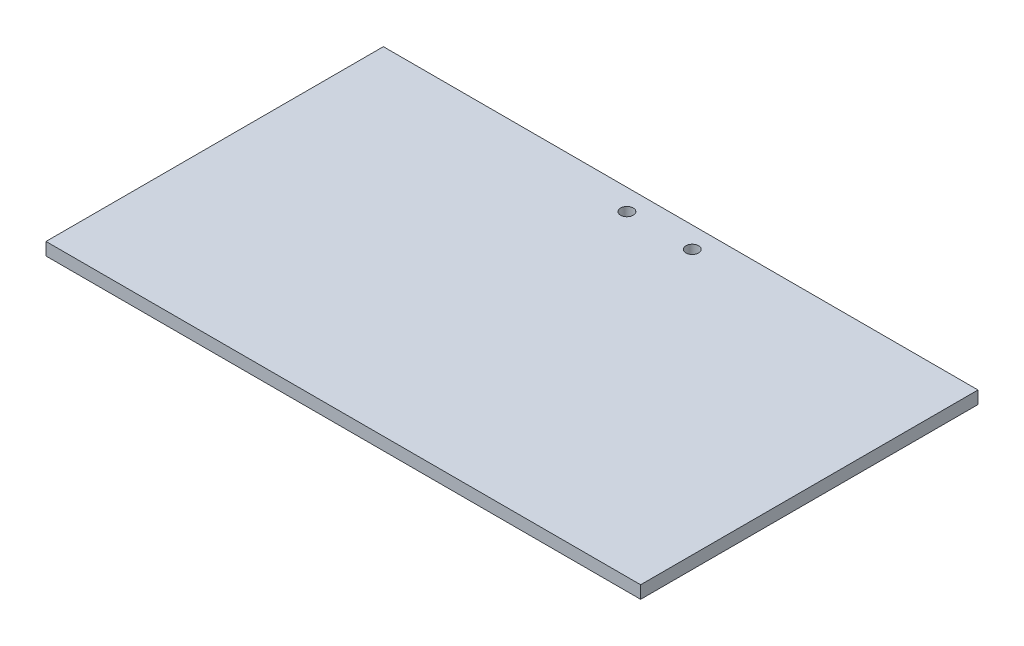
from build123d import *

# Parameters (mm, degrees)
SKETCH_1_W          = 141
SKETCH_1_H          = 80
EXTRUDE_1_DEPTH     = 3
SKETCH_2_R          = 1.5
CUT_EXTRUDE_1_DEPTH = 4
SKETCH_3_R          = 1.5
CUT_EXTRUDE_2_DEPTH = 4


with BuildPart() as part:
    # ｽｹｯﾁ1 → ﾎﾞｽ - 押し出し1 (new body)
    with BuildSketch(Plane(origin=(0, 0, 0), x_dir=(1, 0, 0), z_dir=(0, 1, 0))):
        with Locations((-70.5, 40)):
            Rectangle(SKETCH_1_W, SKETCH_1_H)
    extrude(amount=EXTRUDE_1_DEPTH)

    # ｽｹｯﾁ2 → ｶｯﾄ - 押し出し1 (cut, through all)
    with BuildSketch(Plane(origin=(0, 3, 0), x_dir=(1, 0, 0), z_dir=(0, 1, 0))):
        with Locations(Location((-78.25, 75, 0), (0, 0, 270))):  # turned: the seam where the file's is
            Circle(SKETCH_2_R)
    extrude(amount=-CUT_EXTRUDE_1_DEPTH, mode=Mode.SUBTRACT)

    # ｽｹｯﾁ3 → ｶｯﾄ - 押し出し2 (cut, through all)
    with BuildSketch(Plane(origin=(0, 3, 0), x_dir=(1, 0, 0), z_dir=(0, 1, 0))):
        with Locations(Location((-62.75, 75, 0), (0, 0, 270))):  # turned: the seam where the file's is
            Circle(SKETCH_3_R)
    extrude(amount=-CUT_EXTRUDE_2_DEPTH, mode=Mode.SUBTRACT)


solid = part.part
